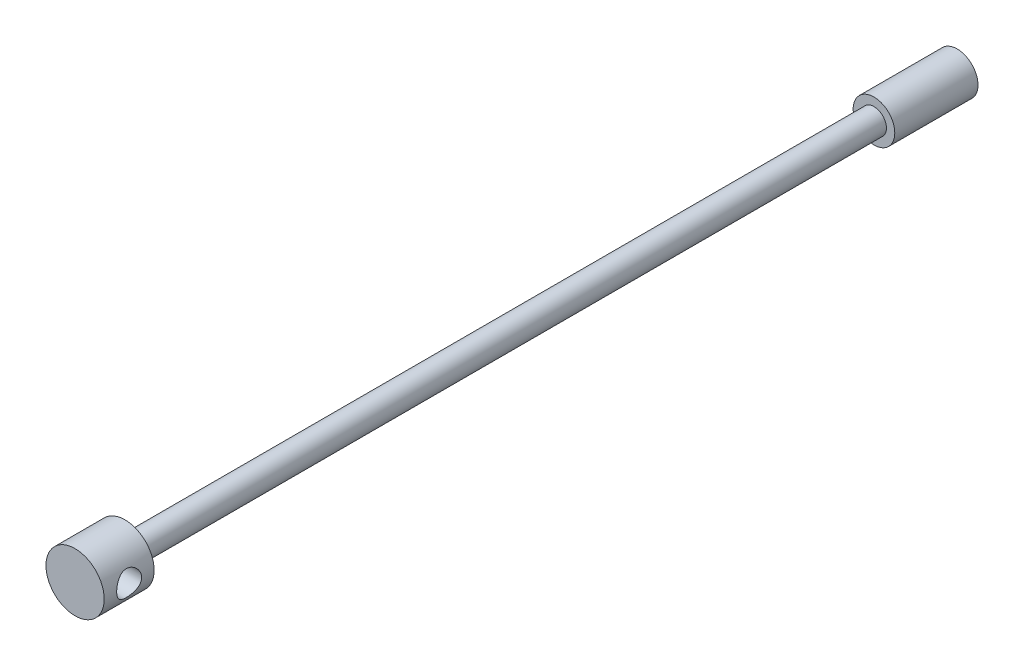
from build123d import *

# Parameters (mm, degrees)
IZIM1_R                     = 1.25
Y_KSEKLIK_EKSTR_ZYON1_DEPTH = 50
IZIM2_R                     = 1.25
IZIM2_R_2                   = 0.75
KES_EKSTR_ZYON1_DEPTH       = 45
IZIM3_R                     = 1.75
Y_KSEKLIK_EKSTR_ZYON2_DEPTH = 3
IZIM4_R                     = 0.75
KES_EKSTR_ZYON2_DEPTH       = 4.5


with BuildPart() as part:
    # Çizim1 → Yükseklik-Ekstrüzyon1 (new body)
    with BuildSketch(Plane.XY):
        Circle(IZIM1_R)
    extrude(amount=Y_KSEKLIK_EKSTR_ZYON1_DEPTH)

    # Çizim2 → Kes-Ekstrüzyon1 (cut)
    with BuildSketch(Plane.XY.offset(50)):
        Circle(IZIM2_R)
        Circle(IZIM2_R_2, mode=Mode.SUBTRACT)
    extrude(amount=-KES_EKSTR_ZYON1_DEPTH, mode=Mode.SUBTRACT)

    # Çizim3 → Yükseklik-Ekstrüzyon2 (add)
    with BuildSketch(Plane.XY.offset(50)):
        Circle(IZIM3_R)
    extrude(amount=Y_KSEKLIK_EKSTR_ZYON2_DEPTH)

    # Çizim4 → Kes-Ekstrüzyon2 (cut, through all)
    with BuildSketch(Plane(origin=(1.75, 0, 0), x_dir=(0, 0, -1), z_dir=(1, 0, 0))):
        with Locations((-51.5, 0)):
            Circle(IZIM4_R)
    extrude(amount=-KES_EKSTR_ZYON2_DEPTH, mode=Mode.SUBTRACT)


solid = part.part
